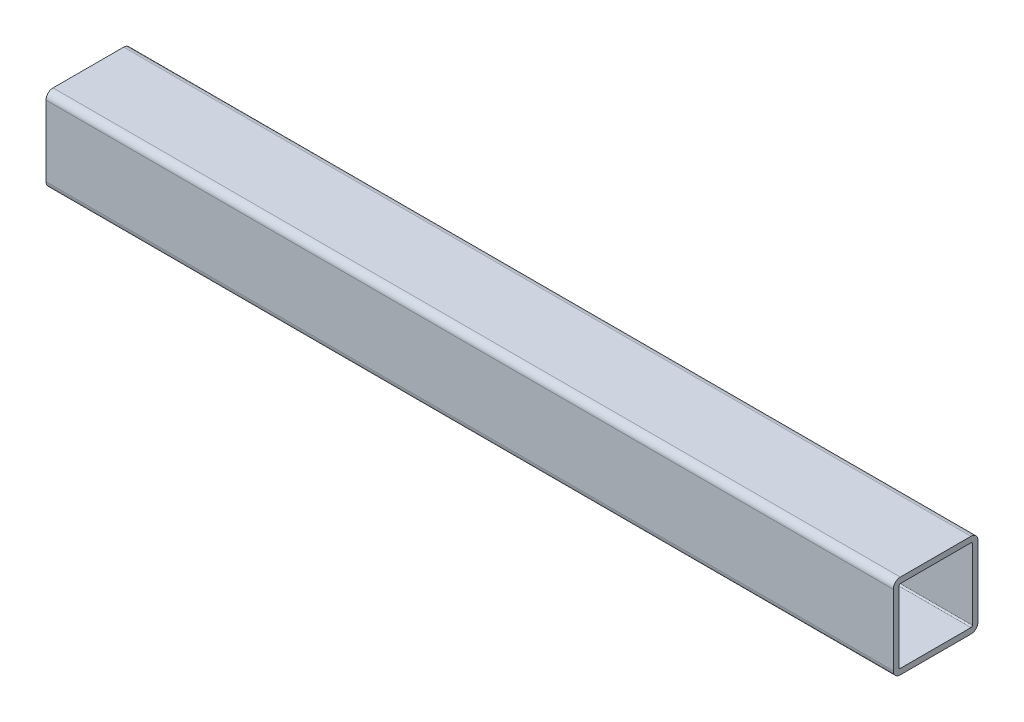
from build123d import *

# Parameters (mm, degrees)
EXTRUDE_THIN1_DEPTH = 190.5


with BuildPart() as part:
    # Sketch1 → Extrude-Thin1 (new body, symmetric)
    with BuildSketch(Plane(origin=(0, 0, 0), x_dir=(0, 0, -1), z_dir=(1, 0, 0))):
        with BuildLine():
            Line((-15.875, 19.05), (15.875, 19.05))
            ThreePointArc((15.875, 19.05), (18.12006403, 18.12006403), (19.05, 15.875))
            Line((19.05, 15.875), (19.05, -15.875))
            ThreePointArc((19.05, -15.875), (18.12006403, -18.12006403), (15.875, -19.05))
            Line((15.875, -19.05), (-15.875, -19.05))
            ThreePointArc((-15.875, -19.05), (-18.12006403, -18.12006403), (-19.05, -15.875))
            Line((-19.05, -15.875), (-19.05, 15.875))
            ThreePointArc((-19.05, 15.875), (-18.12006403, 18.12006403), (-15.875, 19.05))
        make_face()
        with BuildLine():
            Line((-15.875, 16.51), (15.875, 16.51))
            ThreePointArc((15.875, 16.51), (16.324012806, 16.324012806), (16.51, 15.875))
            Line((16.51, 15.875), (16.51, -15.875))
            ThreePointArc((16.51, -15.875), (16.324012806, -16.324012806), (15.875, -16.51))
            Line((15.875, -16.51), (-15.875, -16.51))
            ThreePointArc((-15.875, -16.51), (-16.324012806, -16.324012806), (-16.51, -15.875))
            Line((-16.51, -15.875), (-16.51, 15.875))
            ThreePointArc((-16.51, 15.875), (-16.324012806, 16.324012806), (-15.875, 16.51))
        make_face(mode=Mode.SUBTRACT)
    extrude(amount=EXTRUDE_THIN1_DEPTH, both=True)


solid = part.part
